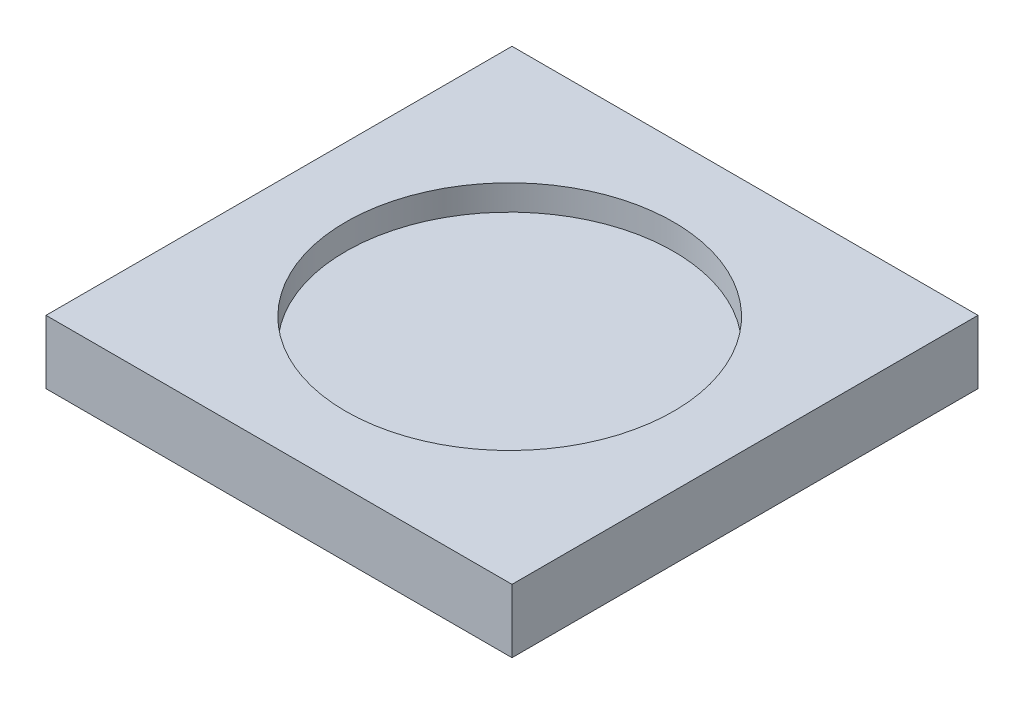
from build123d import *

# Parameters (mm, degrees)
SKETCH1_W           = 36.666666667
SKETCH1_H           = 36.666666667
BOSS_EXTRUDE1_DEPTH = 5
SKETCH2_R           = 12.9
CUT_EXTRUDE1_DEPTH  = 2


with BuildPart() as part:
    # Sketch1 → Boss-Extrude1 (new body)
    with BuildSketch(Plane(origin=(0, 0, 0), x_dir=(1, 0, 0), z_dir=(0, 1, 0))):
        with Locations((-18.333333334, 18.333333334)):
            Rectangle(SKETCH1_W, SKETCH1_H)
    extrude(amount=BOSS_EXTRUDE1_DEPTH)

    # Sketch2 → Cut-Extrude1 (cut)
    with BuildSketch(Plane(origin=(0, 5, 0), x_dir=(1, 0, 0), z_dir=(0, 1, 0))):
        with Locations((-18.333333333, 18.150294579)):
            Circle(SKETCH2_R)
    extrude(amount=-CUT_EXTRUDE1_DEPTH, mode=Mode.SUBTRACT)


solid = part.part
